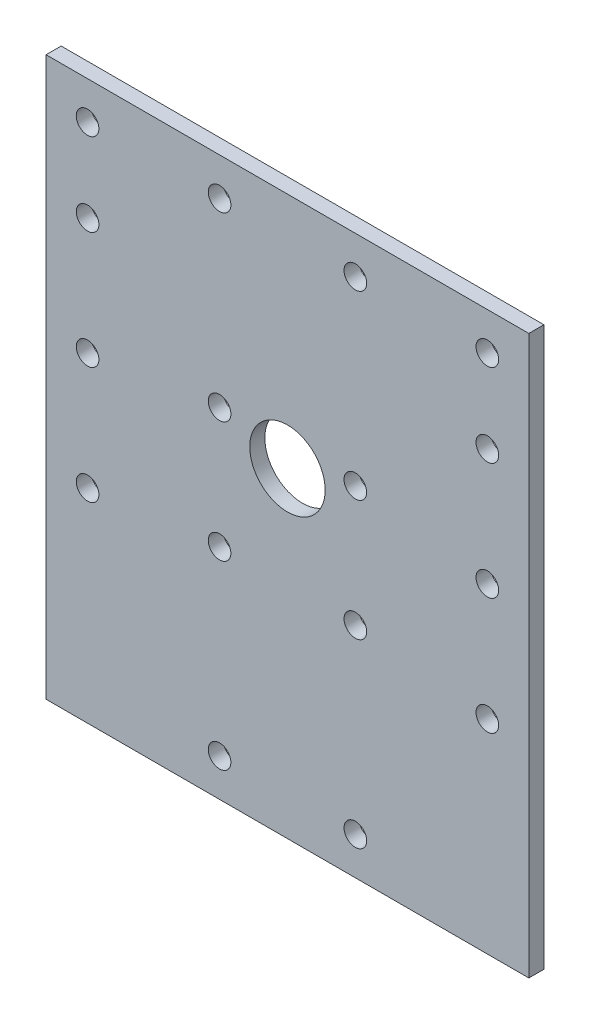
from build123d import *

# Parameters (mm, degrees)
SKETCH1_W           = 64.001099834
SKETCH1_H           = 74
SKETCH1_R           = 1.5
SKETCH1_R_2         = 5
BOSS_EXTRUDE1_DEPTH = 2


with BuildPart() as part:
    # Sketch1 → Boss-Extrude1 (new body)
    with BuildSketch(Plane.XY):
        Rectangle(SKETCH1_W, SKETCH1_H)
        with Locations((-9, 8)):
            Circle(SKETCH1_R, mode=Mode.SUBTRACT)
        with Locations((26.5, -10)):
            Circle(SKETCH1_R, mode=Mode.SUBTRACT)
        with Locations((-9, 32)):
            Circle(SKETCH1_R, mode=Mode.SUBTRACT)
        with Locations((-9, -32)):
            Circle(SKETCH1_R, mode=Mode.SUBTRACT)
        with Locations((-9, -8)):
            Circle(SKETCH1_R, mode=Mode.SUBTRACT)
        with Locations((26.5, 5.5)):
            Circle(SKETCH1_R, mode=Mode.SUBTRACT)
        with Locations((26.5, 21)):
            Circle(SKETCH1_R, mode=Mode.SUBTRACT)
        with Locations((26.5, 32)):
            Circle(SKETCH1_R, mode=Mode.SUBTRACT)
        with Locations((9, 32)):
            Circle(SKETCH1_R, mode=Mode.SUBTRACT)
        with Locations((9, 8)):
            Circle(SKETCH1_R, mode=Mode.SUBTRACT)
        with Locations((9, -8)):
            Circle(SKETCH1_R, mode=Mode.SUBTRACT)
        with Locations((9, -32)):
            Circle(SKETCH1_R, mode=Mode.SUBTRACT)
        with Locations((-26.5, -10)):
            Circle(SKETCH1_R, mode=Mode.SUBTRACT)
        with Locations((-26.5, 5.5)):
            Circle(SKETCH1_R, mode=Mode.SUBTRACT)
        with Locations((-26.5, 21)):
            Circle(SKETCH1_R, mode=Mode.SUBTRACT)
        with Locations((-26.5, 32)):
            Circle(SKETCH1_R, mode=Mode.SUBTRACT)
        with Locations((0, 5.5)):
            Circle(SKETCH1_R_2, mode=Mode.SUBTRACT)
    extrude(amount=BOSS_EXTRUDE1_DEPTH)


solid = part.part
